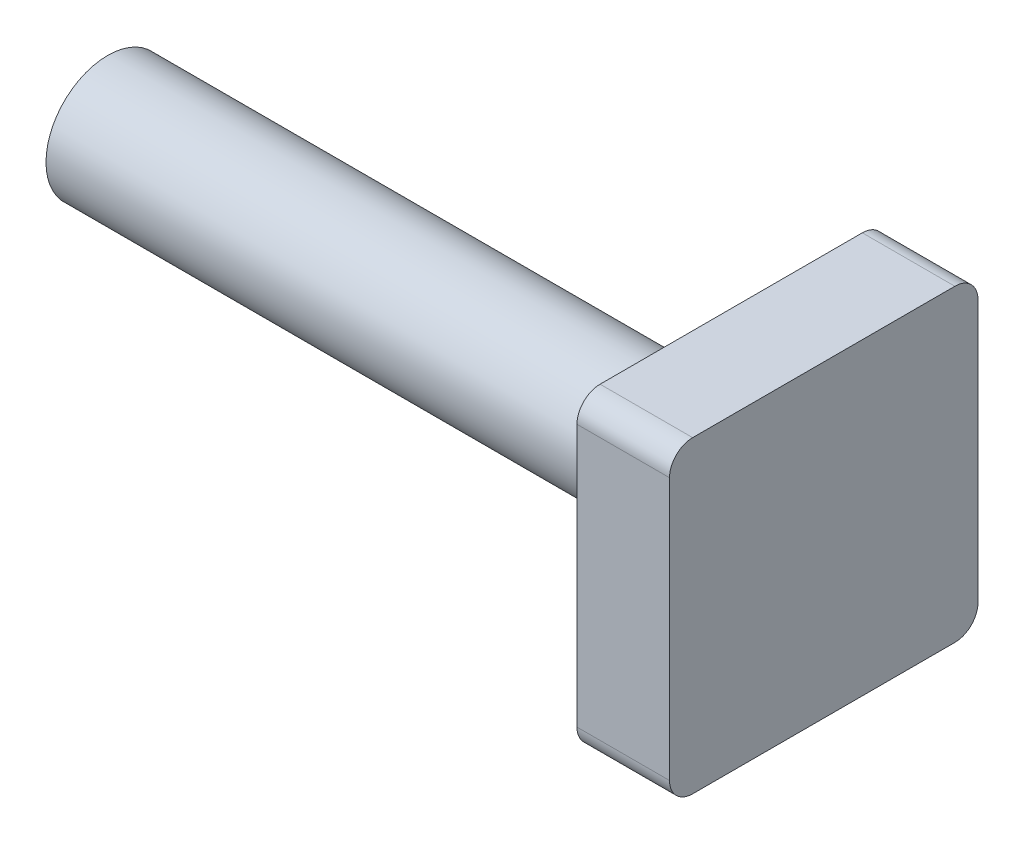
from build123d import *

# Parameters (mm, degrees)
SKETCH1_W      = 10
SKETCH1_H      = 10
HEAD_DEPTH     = 3
SKETCH2_R      = 2
SHAFT_DEPTH    = 20.5
HEAD_FILLET_R  = 0.75
FILLET1_R      = 0.5
CHAMFER1_SIZE  = 0.5
CHAMFER1_SIZE2 = 0.288675135


with BuildPart() as part:
    # Sketch1 → head (new body)
    with BuildSketch(Plane(origin=(0, 0, 0), x_dir=(0, 0, -1), z_dir=(1, 0, 0))):
        Rectangle(SKETCH1_W, SKETCH1_H)
    extrude(amount=HEAD_DEPTH)

    # Sketch2 → shaft (add)
    with BuildSketch(Plane.ZY):
        with Locations(Location((0, 0, 0), (0, 0, 180))):  # turned: the seam where the file's is
            Circle(SKETCH2_R)
    extrude(amount=SHAFT_DEPTH)

    # head fillet
    head_fillet_edges = [part.edges().sort_by_distance(p)[0] for p in [
        (1.5, 5, 5),
        (1.5, 5, -5),
        (1.5, -5, -5),
        (1.5, -5, 5),
    ]]
    fillet(head_fillet_edges, radius=HEAD_FILLET_R)

    # Fillet1
    fillet1_edges = [part.edges().sort_by_distance(p)[0] for p in [
        (0, 0, 2),
    ]]
    fillet(fillet1_edges, radius=FILLET1_R)

    # Chamfer1
    chamfer1_edges = [part.edges().sort_by_distance(p)[0] for p in [
        (-20.5, 0, 2),
    ]]
    chamfer1_side = [part.faces().sort_by_distance(p)[0] for p in [
        (-20.5, 0, 0),
    ]]
    chamfer(chamfer1_edges, length=CHAMFER1_SIZE, length2=CHAMFER1_SIZE2, reference=chamfer1_side[0])


solid = part.part
